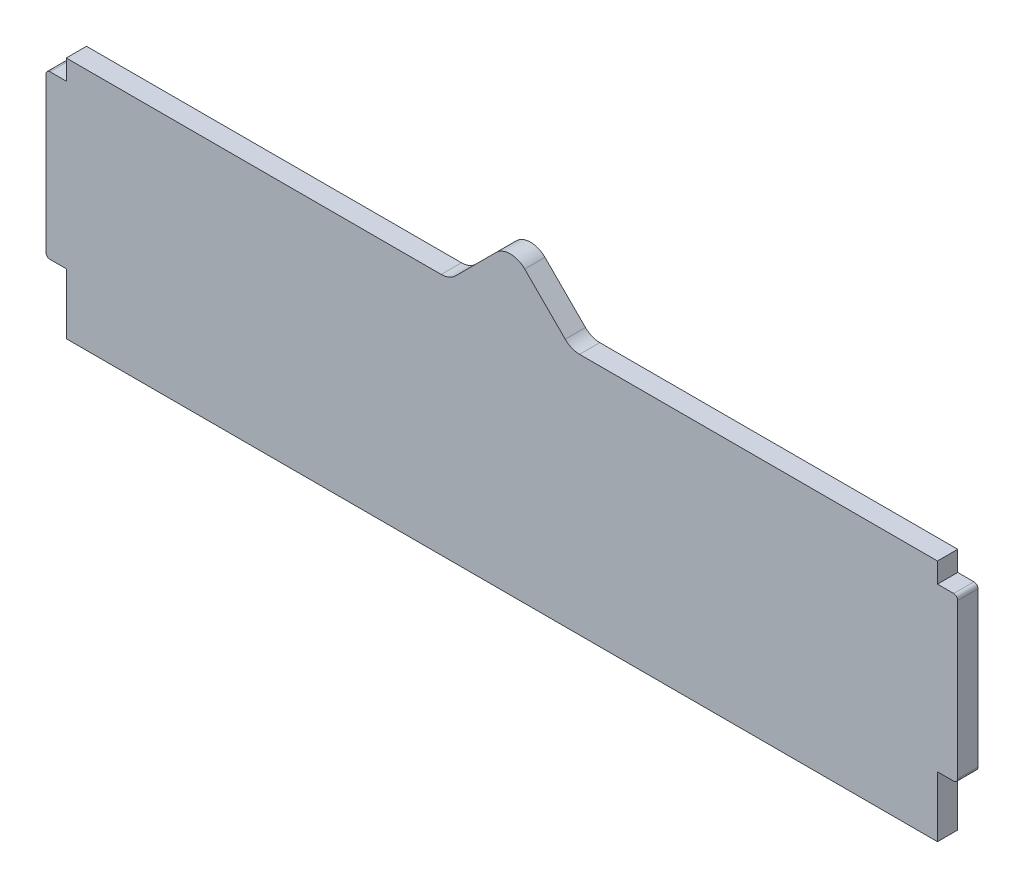
from build123d import *

# Parameters (mm, degrees)
BOSS_EXTRUDE1_DEPTH = 5
FILLET1_R           = 5
FILLET2_R           = 1


with BuildPart() as part:
    # Sketch1 → Boss-Extrude1 (new body)
    with BuildSketch(Plane.XY):
        Polygon((215, 55.05), (215, 60), (124.595635172, 60), (109.595635172, 75), (94.595635172, 60), (0, 60), (0, 55.05), (-5, 55.05), (-5, 14.95), (0, 14.95), (0, 0), (215, 0), (215, 14.95), (220, 14.95), (220, 55.05), align=None)
    extrude(amount=BOSS_EXTRUDE1_DEPTH)

    # Fillet1
    fillet1_edges = [part.edges().sort_by_distance(p)[0] for p in [
        (94.595635172, 60, 2.5),
        (109.595635172, 75, 2.5),
        (124.595635172, 60, 2.5),
    ]]
    fillet(fillet1_edges, radius=FILLET1_R)

    # Fillet2
    fillet2_edges = [part.edges().sort_by_distance(p)[0] for p in [
        (-5, 14.95, 2.5),
        (-5, 55.05, 2.5),
        (220, 55.05, 2.5),
        (220, 14.95, 2.5),
    ]]
    fillet(fillet2_edges, radius=FILLET2_R)


solid = part.part
